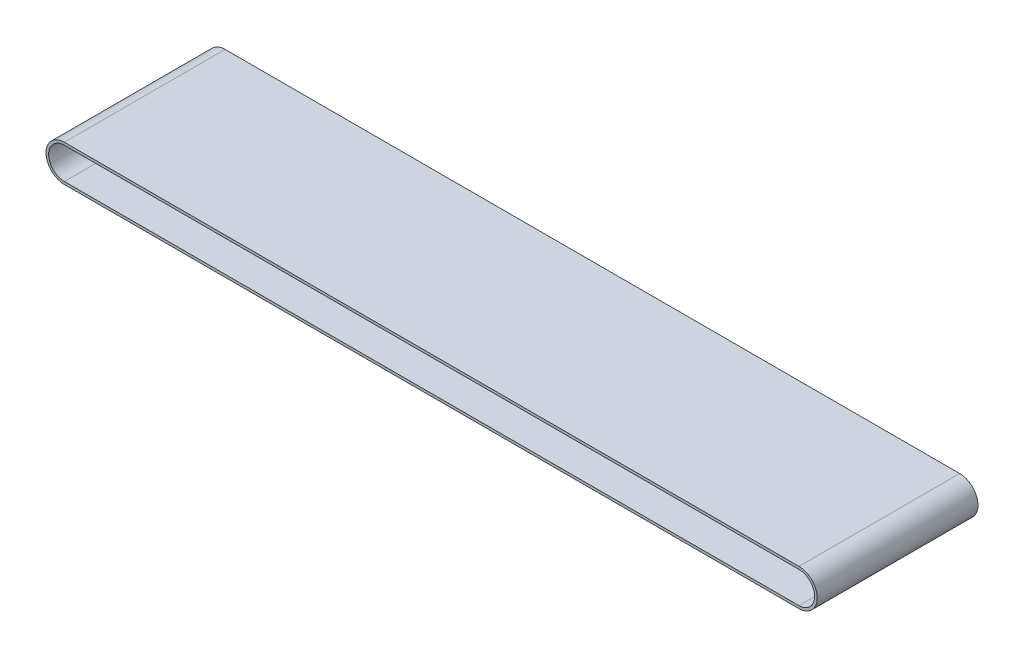
from build123d import *

# Parameters (mm, degrees)
BOSS_EXTRUDE1_DEPTH = 123


with BuildPart() as part:
    # Sketch1 → Boss-Extrude1 (new body)
    with BuildSketch(Plane.XY):
        with BuildLine():
            Line((-281, 14), (281, 14))
            ThreePointArc((281, 14), (295, 0), (281, -14))
            Line((281, -14), (-281, -14))
            ThreePointArc((-281, -14), (-295, 0), (-281, 14))
        make_face()
        with BuildLine():
            Line((-281, 12), (281, 12))
            ThreePointArc((281, 12), (293, 0), (281, -12))
            Line((281, -12), (-281, -12))
            ThreePointArc((-281, -12), (-293, 0), (-281, 12))
        make_face(mode=Mode.SUBTRACT)
    extrude(amount=BOSS_EXTRUDE1_DEPTH)


solid = part.part
